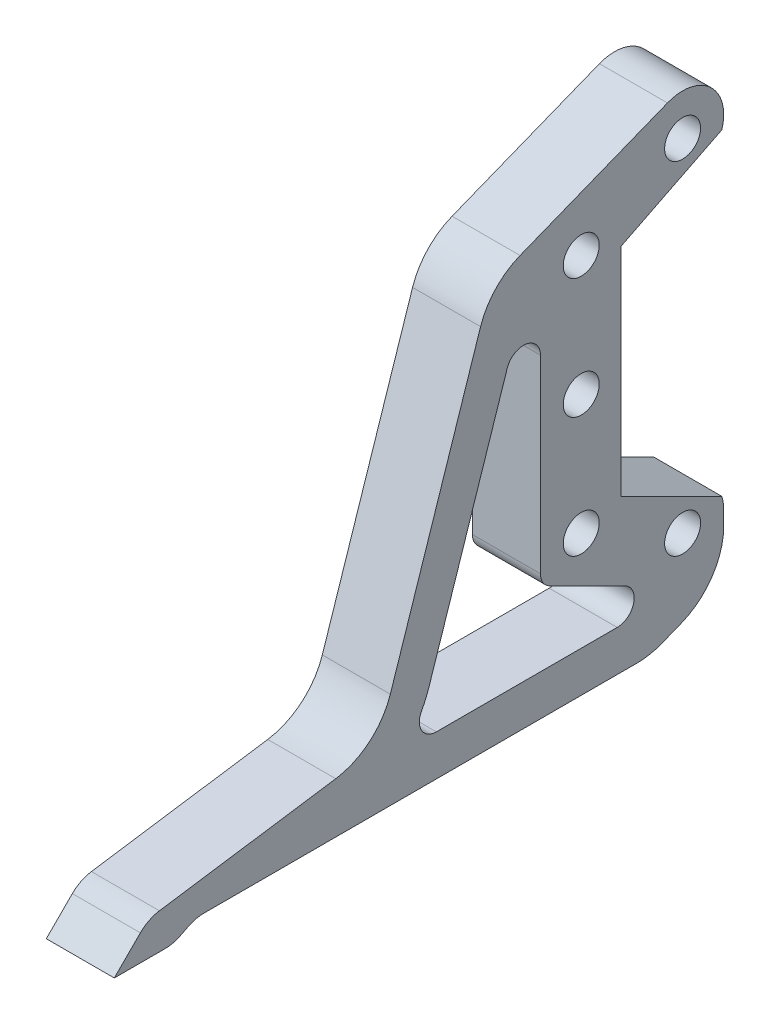
from build123d import *

# Parameters (mm, degrees)
SKETCH1_R               = 7.9375
SKETCH1_R_2             = 11.1125
BOSS_EXTRUDE1_DEPTH     = 12.7
F_8_CLEARANCE_HOLE1_D   = 4.4958
SKETCH5_R               = 18.415
CUT_EXTRUDE1_DEPTH      = 13.7
SKETCH7_R               = 9.525
CUT_EXTRUDE2_DEPTH      = 13.7
CUT_EXTRUDE3_DEPTH      = 13.7
BOSS_EXTRUDE2_DEPTH     = 12.7
CUT_EXTRUDE4_DEPTH      = 13.7
SKETCH11_W              = 12.7
SKETCH11_H              = 178.054
CUT_EXTRUDE5_DEPTH      = 3.175
BOSS_EXTRUDE3_DEPTH     = 19.05
CUT_EXTRUDE6_DEPTH      = 20.05
F_3_8_CLEARANCE_HOLE1_D = 10.0838
CUT_EXTRUDE7_DEPTH      = 20.05
BOSS_EXTRUDE4_DEPTH     = 19.05
FILLET1_R               = 19.05
FILLET2_R               = 9.525
CUT_EXTRUDE8_DEPTH      = 20.05
BOSS_EXTRUDE5_DEPTH     = 19.05
FILLET3_R               = 4.7625


with BuildPart() as part:
    # Sketch1 → Boss-Extrude1 (new body)
    with BuildSketch(Plane(origin=(0, 0, 0), x_dir=(0, 0, -1), z_dir=(1, 0, 0))):
        with BuildLine():
            Line((93.345, 0), (55.245, 50.8))
            Line((55.245, 50.8), (-160.655, 50.8))
            ThreePointArc((-160.655, 50.8), (-211.455, 0), (-160.655, -50.8))
            Line((-160.655, -50.8), (55.245, -50.8))
            Line((55.245, -50.8), (93.345, 0))
        make_face()
        with Locations((-88.9, 0)):
            Circle(SKETCH1_R, mode=Mode.SUBTRACT)
        with Locations((-38.1, 0)):
            Circle(SKETCH1_R, mode=Mode.SUBTRACT)
        with Locations((-160.655, 0)):
            Circle(SKETCH1_R_2, mode=Mode.SUBTRACT)
        Circle(SKETCH1_R, mode=Mode.SUBTRACT)
    extrude(amount=BOSS_EXTRUDE1_DEPTH)

    # #8 Clearance Hole1 (through all)
    with Locations(Plane.ZY):
        with Locations((-17.691104559, 17.691104559), (17.691104559, 17.691104559), (17.691104559, -17.691104559), (-17.691104559, -17.691104559)):
            Hole(F_8_CLEARANCE_HOLE1_D / 2)

    # Sketch5 → Cut-Extrude1 (cut, through all)
    with BuildSketch(Plane.ZY):
        Circle(SKETCH5_R)
    extrude(amount=-CUT_EXTRUDE1_DEPTH, mode=Mode.SUBTRACT)

    # Sketch7 → Cut-Extrude2 (cut, through all)
    with BuildSketch(Plane.ZY):
        with Locations((-55.245, 0)):
            Circle(SKETCH7_R)
    extrude(amount=-CUT_EXTRUDE2_DEPTH, mode=Mode.SUBTRACT)

    # Sketch8 → Cut-Extrude3 (cut, through all)
    with BuildSketch(Plane(origin=(12.7, 0, 0), x_dir=(0, 0, -1), z_dir=(1, 0, 0))):
        Polygon((-160.655, 50.8), (-211.455, 25.4), (-211.455, -25.4), (-160.655, -50.8), (-233.239745749, -50.8), (-233.239745749, 50.8), align=None)
    extrude(amount=-CUT_EXTRUDE3_DEPTH, mode=Mode.SUBTRACT)

    # Sketch9 → Boss-Extrude2 (add)
    with BuildSketch(Plane(origin=(12.7, 0, 0), x_dir=(0, 0, -1), z_dir=(1, 0, 0))):
        Polygon((-160.655, 50.8), (-211.455, 25.4), (-211.455, 0), (-211.455, -25.4), (-160.655, -50.8), (-160.655, -40.64), (-202.749323348, 0), (-160.655, 40.64), align=None)
    extrude(amount=-BOSS_EXTRUDE2_DEPTH)

    # Sketch10 → Cut-Extrude4 (cut, through all)
    with BuildSketch(Plane.ZY):
        Polygon((-79.0575, -19.05), (-79.0575, 19.05), (-93.345, 0), align=None)
    extrude(amount=-CUT_EXTRUDE4_DEPTH, mode=Mode.SUBTRACT)

    # Sketch11 → Cut-Extrude5 (cut)
    with BuildSketch(Plane(origin=(0, 50.8, 0), x_dir=(1, 0, 0), z_dir=(0, 1, 0))):
        with Locations((6.35, -52.705)):
            Rectangle(SKETCH11_W, SKETCH11_H)
    cut_extrude5 = extrude(amount=-CUT_EXTRUDE5_DEPTH, mode=Mode.SUBTRACT)

    # Mirror1: Cut-Extrude5 across plane
    add(cut_extrude5.mirror(Plane.ZX), mode=Mode.SUBTRACT)

    # Sketch13 → Cut-Extrude6 (cut, through all)
    with BuildSketch(Plane(origin=(12.7, 0, 0), x_dir=(0, 0, -1), z_dir=(1, 0, 0))):
        Polygon((-161.254612663, -53.34), (-139.192, -53.34), (-139.192, -50.165), (33.782, -50.165), (33.782, -53.34), (56.515, -53.34), (81.5975, -19.896666667), (81.5975, 19.896666667), (56.515, 53.34), (33.782, 53.34), (33.782, 50.165), (-139.192, 50.165), (-139.192, 53.34), (-161.254612663, 53.34), (-213.995, 26.969806331), (-213.995, -26.969806331), align=None)
    extrude(amount=-CUT_EXTRUDE6_DEPTH, mode=Mode.SUBTRACT)


with BuildPart() as body_2:
    # Sketch12 → Boss-Extrude3 (new body)
    with BuildSketch(Plane(origin=(12.7, 0, 0), x_dir=(0, 0, -1), z_dir=(1, 0, 0))):
        with BuildLine():
            ThreePointArc((-211.89681554, -56.397839854), (-236.855, 0), (-211.89681554, 56.397839854))
            Line((-211.89681554, 56.397839854), (-243.205, 43.989212666))
            Line((-243.205, 43.989212666), (-243.205, -43.989212666))
            Line((-243.205, -43.989212666), (-211.89681554, -56.397839854))
        make_face()
        with BuildLine():
            Line((-217.805, 29.324515829), (-162.154031657, 57.15))
            Line((-162.154031657, 57.15), (-166.916531657, 66.675))
            Line((-166.916531657, 66.675), (-185.966531657, 66.675))
            Line((-185.966531657, 66.675), (-211.89681554, 56.397839854))
            ThreePointArc((-211.89681554, 56.397839854), (-236.855, 0), (-211.89681554, -56.397839854))
            Line((-211.89681554, -56.397839854), (-185.966531657, -66.675))
            Line((-185.966531657, -66.675), (-166.916531657, -66.675))
            Line((-166.916531657, -66.675), (-162.154031657, -57.15))
            Line((-162.154031657, -57.15), (-217.805, -29.324515829))
            Line((-217.805, -29.324515829), (-217.805, 29.324515829))
        make_face()
    extrude(amount=-BOSS_EXTRUDE3_DEPTH)

    # 3/8 Clearance Hole1 (through all)
    with Locations(Plane(origin=(12.7, 0, 0), x_dir=(0, 0, -1), z_dir=(1, 0, 0))):
        with Locations((-230.505, 0), (-230.505, 33.690140829), (-202.106936686, 47.889172486), (-230.505, -33.690140829), (-202.106936686, -47.889172486)):
            Hole(F_3_8_CLEARANCE_HOLE1_D / 2)

    # Sketch16 → Cut-Extrude7 (cut, through all)
    with BuildSketch(Plane(origin=(12.7, 0, 0), x_dir=(0, 0, -1), z_dir=(1, 0, 0))):
        with BuildLine():
            ThreePointArc((-190.589767426, 47.889172486), (-190.722432786, 46.146112328), (-191.117372542, 44.443208515))
            Line((-191.117372542, 44.443208515), (-162.86398324, 58.569903166))
            Line((-162.86398324, 58.569903166), (-166.916531657, 66.675))
            Line((-166.916531657, 66.675), (-185.966531657, 66.675))
            Line((-185.966531657, 66.675), (-206.35048523, 58.596062021))
            ThreePointArc((-206.35048523, 58.596062021), (-195.635015761, 57.415946719), (-190.589767426, 47.889172486))
        make_face()
        with BuildLine():
            Line((-162.86398324, 58.569903166), (-191.117372542, 44.443208515))
            ThreePointArc((-191.117372542, 44.443208515), (-191.551739911, 43.281243579), (-192.108559765, 42.172735946))
            Line((-192.108559765, 42.172735946), (-162.154031657, 57.15))
            Line((-162.154031657, 57.15), (-162.86398324, 58.569903166))
        make_face()
        with BuildLine():
            Line((-191.117372542, 44.443208515), (-205.943903995, 37.029942788))
            ThreePointArc((-205.943903995, 37.029942788), (-204.753711625, 36.680257722), (-203.532813606, 36.460609025))
            Line((-203.532813606, 36.460609025), (-192.108559765, 42.172735946))
            ThreePointArc((-192.108559765, 42.172735946), (-191.551739911, 43.281243579), (-191.117372542, 44.443208515))
        make_face()
        with BuildLine():
            Line((-219.3925, 30.305644786), (-219.3925, -30.305644786))
            Line((-219.3925, -30.305644786), (-205.943903995, -37.029942788))
            ThreePointArc((-205.943903995, -37.029942788), (-204.753711625, -36.680257722), (-203.532813606, -36.460609025))
            Line((-203.532813606, -36.460609025), (-217.805, -29.324515829))
            Line((-217.805, -29.324515829), (-217.805, 29.324515829))
            Line((-217.805, 29.324515829), (-203.532813606, 36.460609025))
            ThreePointArc((-203.532813606, 36.460609025), (-204.753711625, 36.680257722), (-205.943903995, 37.029942788))
            Line((-205.943903995, 37.029942788), (-219.3925, 30.305644786))
        make_face()
        with BuildLine():
            ThreePointArc((-203.532813606, -36.460609025), (-204.753711625, -36.680257722), (-205.943903995, -37.029942788))
            Line((-205.943903995, -37.029942788), (-191.117372542, -44.443208515))
            ThreePointArc((-191.117372542, -44.443208515), (-191.551739911, -43.281243579), (-192.108559765, -42.172735946))
            Line((-192.108559765, -42.172735946), (-203.532813606, -36.460609025))
        make_face()
        with BuildLine():
            ThreePointArc((-192.108559765, -42.172735946), (-191.551739911, -43.281243579), (-191.117372542, -44.443208515))
            Line((-191.117372542, -44.443208515), (-162.86398324, -58.569903166))
            Line((-162.86398324, -58.569903166), (-162.154031657, -57.15))
            Line((-162.154031657, -57.15), (-192.108559765, -42.172735946))
        make_face()
        with BuildLine():
            Line((-162.86398324, -58.569903166), (-191.117372542, -44.443208515))
            ThreePointArc((-191.117372542, -44.443208515), (-190.722432786, -46.146112328), (-190.589767426, -47.889172486))
            Line((-190.589767426, -47.889172486), (-190.589767426, -64.842635395))
            Line((-190.589767426, -64.842635395), (-185.966531657, -66.675))
            Line((-185.966531657, -66.675), (-166.916531657, -66.675))
            Line((-166.916531657, -66.675), (-162.86398324, -58.569903166))
        make_face()
    extrude(amount=-CUT_EXTRUDE7_DEPTH, mode=Mode.SUBTRACT)

    # Sketch17 → Boss-Extrude4 (add)
    with BuildSketch(Plane(origin=(12.7, 0, 0), x_dir=(0, 0, -1), z_dir=(1, 0, 0))):
        Polygon((-338.455, -73.025), (-211.234676528, -73.025), (-190.589767426, -64.842635395), (-243.205, -43.989212666), (-243.205, 43.989212666), (-255.905, 38.955718453), (-287.655, -57.15), (-351.768316876, -66.675), (-361.293316876, -76.2), (-344.805, -76.2), align=None)
    extrude(amount=-BOSS_EXTRUDE4_DEPTH)

    # Fillet1
    fillet1_edges = [body_2.edges().sort_by_distance(p)[0] for p in [
        (3.175, -73.025, 211.234676528),
        (3.175, -57.15, 287.655),
        (3.175, 38.955718453, 255.905),
        (3.175, -64.842635395, 190.589767426),
    ]]
    fillet(fillet1_edges, radius=FILLET1_R)

    # Fillet2
    fillet2_edges = [body_2.edges().sort_by_distance(p)[0] for p in [
        (3.175, -73.025, 338.455),
        (3.175, -76.2, 344.805),
        (3.175, -66.675, 351.768316876),
    ]]
    fillet(fillet2_edges, radius=FILLET2_R)

    # Sketch18 → Cut-Extrude8 (cut, through all)
    with BuildSketch(Plane(origin=(12.7, 0, 0), x_dir=(0, 0, -1), z_dir=(1, 0, 0))):
        with BuildLine():
            ThreePointArc((-273.120706312, -49.592608078), (-276.117108341, -56.027596012), (-280.520687302, -61.595))
            Line((-280.520687302, -61.595), (-214.872157895, -61.595))
            ThreePointArc((-214.872157895, -61.595), (-213.442985613, -61.459775654), (-212.064537448, -61.058901992))
            Line((-212.064537448, -61.058901992), (-206.832146979, -58.985106153))
            ThreePointArc((-206.832146979, -58.985106153), (-206.472989442, -58.831999008), (-206.122145618, -58.660696511))
            Line((-206.122145618, -58.660696511), (-207.218588082, -58.112475279))
            Line((-207.218588082, -58.112475279), (-241.935, -40.75426932))
            Line((-241.935, -40.75426932), (-241.935, 32.197558556))
            Line((-241.935, 32.197558556), (-243.416943097, 31.610208005))
            ThreePointArc((-243.416943097, 31.610208005), (-246.152147631, 29.755215195), (-247.844705879, 26.916625978))
            Line((-247.844705879, 26.916625978), (-273.120706312, -49.592608078))
        make_face()
    extrude(amount=-CUT_EXTRUDE8_DEPTH, mode=Mode.SUBTRACT)

    # Sketch19 → Boss-Extrude5 (add)
    with BuildSketch(Plane(origin=(12.7, 0, 0), x_dir=(0, 0, -1), z_dir=(1, 0, 0))):
        with BuildLine():
            ThreePointArc((-243.416943097, 31.610208005), (-246.152147631, 29.755215195), (-247.844705879, 26.916625978))
            Line((-247.844705879, 26.916625978), (-251.219614601, 16.700940075))
            ThreePointArc((-251.219614601, 16.700940075), (-245.940917069, 19.909009969), (-241.935, 15.206990348))
            Line((-241.935, 15.206990348), (-241.935, 32.197558556))
            Line((-241.935, 32.197558556), (-243.416943097, 31.610208005))
        make_face()
        with BuildLine():
            ThreePointArc((-271.08233553, -61.595), (-275.17466524, -59.268530337), (-275.268808735, -54.562070888))
            ThreePointArc((-275.268808735, -54.562070888), (-277.640258261, -58.268577072), (-280.520687302, -61.595))
            Line((-280.520687302, -61.595), (-271.08233553, -61.595))
        make_face()
        with BuildLine():
            Line((-206.122145618, -58.660696511), (-218.297957405, -52.572790618))
            ThreePointArc((-218.297957405, -52.572790618), (-216.376587841, -54.328705688), (-215.665312383, -56.8325))
            ThreePointArc((-215.665312383, -56.8325), (-217.060216337, -60.200096045), (-220.427812383, -61.595))
            Line((-220.427812383, -61.595), (-214.872157895, -61.595))
            ThreePointArc((-214.872157895, -61.595), (-213.442985613, -61.459775654), (-212.064537448, -61.058901992))
            Line((-212.064537448, -61.058901992), (-206.832146979, -58.985106153))
            ThreePointArc((-206.832146979, -58.985106153), (-206.472989442, -58.831999008), (-206.122145618, -58.660696511))
        make_face()
    extrude(amount=-BOSS_EXTRUDE5_DEPTH)

    # Fillet3
    fillet3_edges = [body_2.edges().sort_by_distance(p)[0] for p in [
        (3.175, -40.75426932, 241.935),
    ]]
    fillet(fillet3_edges, radius=FILLET3_R)


solid = body_2.part
